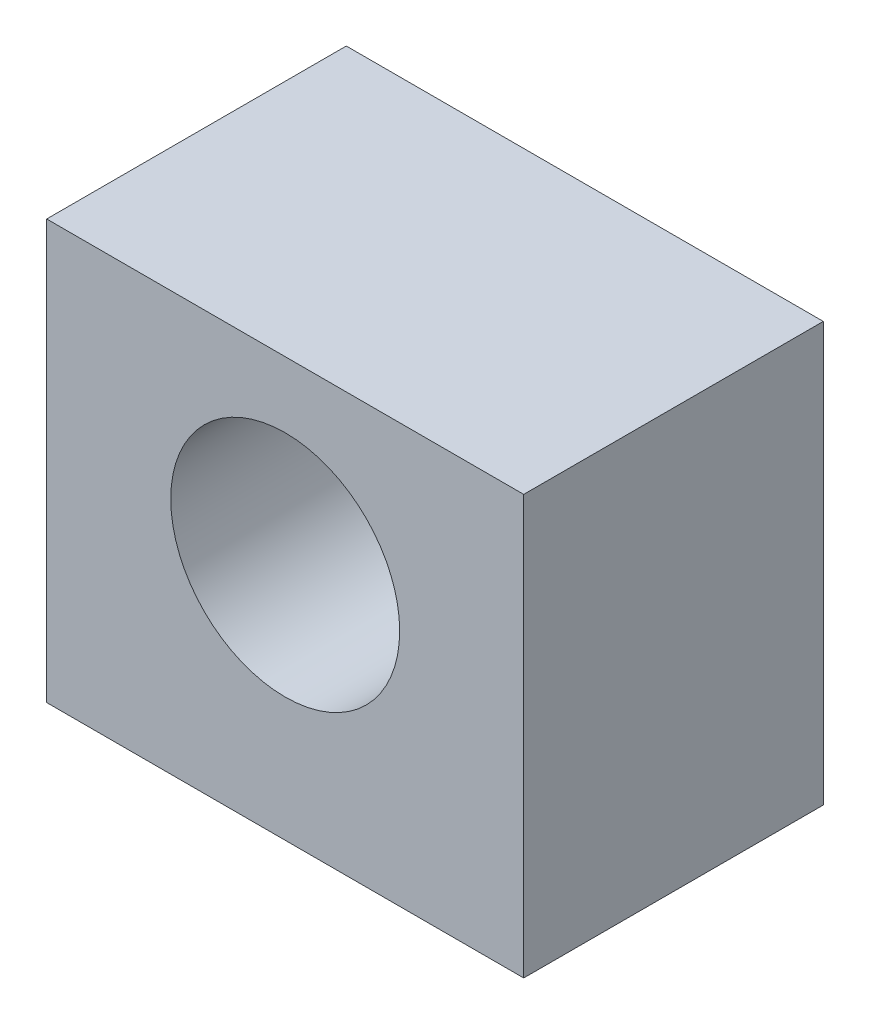
from build123d import *

# Parameters (mm, degrees)
BOSS_EXTRUDE1_DEPTH = 5.15
SKETCH2_R           = 1.9675
CUT_EXTRUDE1_DEPTH  = 6.15


with BuildPart() as part:
    # Sketch1 → Boss-Extrude1 (new body)
    with BuildSketch(Plane.XY):
        Polygon((-0.1, -0.1), (3, -0.1), (7, -0.1), (8.1, -0.1), (8.1, 7.1), (-0.1, 7.1), align=None)
    extrude(amount=BOSS_EXTRUDE1_DEPTH)

    # Sketch2 → Cut-Extrude1 (cut, through all)
    with BuildSketch(Plane.XY.offset(5.15)):
        with Locations((4, 4)):
            Circle(SKETCH2_R)
    extrude(amount=-CUT_EXTRUDE1_DEPTH, mode=Mode.SUBTRACT)


solid = part.part
